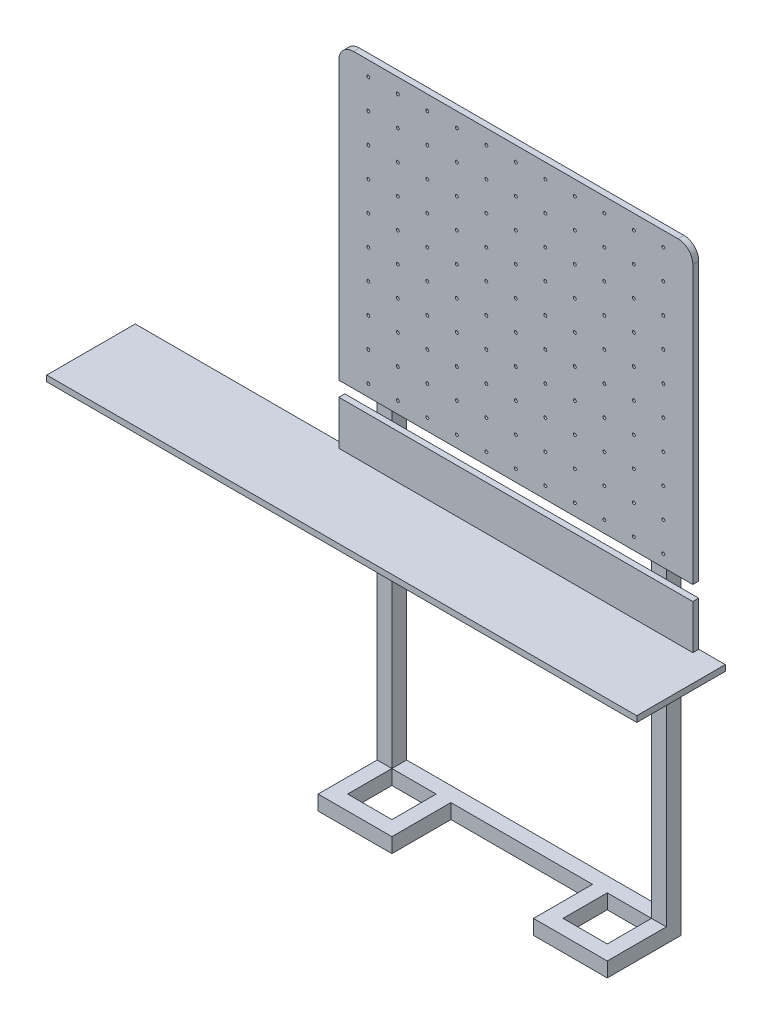
from build123d import *

# Parameters (mm, degrees)
CROQUIS1_W               = 1200
CROQUIS1_H               = 990
SALIENTE_EXTRUIR1_DEPTH  = 20
CROQUIS2_R               = 5
CORTAR_EXTRUIR1_DEPTH    = 21
CROQUIS3_W               = 50
CROQUIS3_H               = 50
SALIENTE_EXTRUIR2_DEPTH  = 50
CROQUIS7_W               = 50
CROQUIS7_H               = 50
SALIENTE_EXTRUIR4_DEPTH  = 2000
CROQUIS8_W               = 2000
CROQUIS8_H               = 20
SALIENTE_EXTRUIR5_DEPTH  = 300
CROQUIS9_W               = 1200
CROQUIS9_H               = 20
SALIENTE_EXTRUIR6_DEPTH  = 150
REDONDEO1_R              = 50
SALIENTE_EXTRUIR7_REACH  = 1752
CROQUIS10_W              = 50
CROQUIS10_H              = 50
SALIENTE_EXTRUIR8_REACH  = 1752
CROQUIS11_W              = 50
CROQUIS11_H              = 50
SALIENTE_EXTRUIR9_DEPTH  = 50
CROQUIS13_W              = 940
CROQUIS13_H              = 10
SALIENTE_EXTRUIR10_DEPTH = 10


with BuildPart() as part:
    # Croquis1 → Saliente-Extruir1 (new body)
    with BuildSketch(Plane.XY):
        Rectangle(CROQUIS1_W, CROQUIS1_H)
    extrude(amount=SALIENTE_EXTRUIR1_DEPTH)

    # Croquis2 → Cortar-Extruir1 (cut, through all)
    with BuildSketch(Plane.XY.offset(20)):
        with Locations((-500, 445)):
            Circle(CROQUIS2_R)
        with Locations((-400, 445)):
            Circle(CROQUIS2_R)
        with Locations((-300, 445)):
            Circle(CROQUIS2_R)
        with Locations((-200, 445)):
            Circle(CROQUIS2_R)
        with Locations((-100, 445)):
            Circle(CROQUIS2_R)
        with Locations((0, 445)):
            Circle(CROQUIS2_R)
        with Locations((100, 445)):
            Circle(CROQUIS2_R)
        with Locations((200, 445)):
            Circle(CROQUIS2_R)
        with Locations((300, 445)):
            Circle(CROQUIS2_R)
        with Locations((400, 445)):
            Circle(CROQUIS2_R)
        with Locations((500, 445)):
            Circle(CROQUIS2_R)
        with Locations((-400, 345)):
            Circle(CROQUIS2_R)
        with Locations((-300, 345)):
            Circle(CROQUIS2_R)
        with Locations((-200, 345)):
            Circle(CROQUIS2_R)
        with Locations((-100, 345)):
            Circle(CROQUIS2_R)
        with Locations((0, 345)):
            Circle(CROQUIS2_R)
        with Locations((100, 345)):
            Circle(CROQUIS2_R)
        with Locations((200, 345)):
            Circle(CROQUIS2_R)
        with Locations((300, 345)):
            Circle(CROQUIS2_R)
        with Locations((400, 345)):
            Circle(CROQUIS2_R)
        with Locations((500, 345)):
            Circle(CROQUIS2_R)
        with Locations((-400, 245)):
            Circle(CROQUIS2_R)
        with Locations((-300, 245)):
            Circle(CROQUIS2_R)
        with Locations((-200, 245)):
            Circle(CROQUIS2_R)
        with Locations((-100, 245)):
            Circle(CROQUIS2_R)
        with Locations((0, 245)):
            Circle(CROQUIS2_R)
        with Locations((100, 245)):
            Circle(CROQUIS2_R)
        with Locations((200, 245)):
            Circle(CROQUIS2_R)
        with Locations((300, 245)):
            Circle(CROQUIS2_R)
        with Locations((400, 245)):
            Circle(CROQUIS2_R)
        with Locations((500, 245)):
            Circle(CROQUIS2_R)
        with Locations((-400, 145)):
            Circle(CROQUIS2_R)
        with Locations((-300, 145)):
            Circle(CROQUIS2_R)
        with Locations((-200, 145)):
            Circle(CROQUIS2_R)
        with Locations((-100, 145)):
            Circle(CROQUIS2_R)
        with Locations((0, 145)):
            Circle(CROQUIS2_R)
        with Locations((100, 145)):
            Circle(CROQUIS2_R)
        with Locations((200, 145)):
            Circle(CROQUIS2_R)
        with Locations((300, 145)):
            Circle(CROQUIS2_R)
        with Locations((400, 145)):
            Circle(CROQUIS2_R)
        with Locations((500, 145)):
            Circle(CROQUIS2_R)
        with Locations((-400, 45)):
            Circle(CROQUIS2_R)
        with Locations((-300, 45)):
            Circle(CROQUIS2_R)
        with Locations((-200, 45)):
            Circle(CROQUIS2_R)
        with Locations((-100, 45)):
            Circle(CROQUIS2_R)
        with Locations((0, 45)):
            Circle(CROQUIS2_R)
        with Locations((100, 45)):
            Circle(CROQUIS2_R)
        with Locations((200, 45)):
            Circle(CROQUIS2_R)
        with Locations((300, 45)):
            Circle(CROQUIS2_R)
        with Locations((400, 45)):
            Circle(CROQUIS2_R)
        with Locations((500, 45)):
            Circle(CROQUIS2_R)
        with Locations((-400, -55)):
            Circle(CROQUIS2_R)
        with Locations((-300, -55)):
            Circle(CROQUIS2_R)
        with Locations((-200, -55)):
            Circle(CROQUIS2_R)
        with Locations((-100, -55)):
            Circle(CROQUIS2_R)
        with Locations((0, -55)):
            Circle(CROQUIS2_R)
        with Locations((100, -55)):
            Circle(CROQUIS2_R)
        with Locations((200, -55)):
            Circle(CROQUIS2_R)
        with Locations((300, -55)):
            Circle(CROQUIS2_R)
        with Locations((400, -55)):
            Circle(CROQUIS2_R)
        with Locations((500, -55)):
            Circle(CROQUIS2_R)
        with Locations((-400, -155)):
            Circle(CROQUIS2_R)
        with Locations((-300, -155)):
            Circle(CROQUIS2_R)
        with Locations((-200, -155)):
            Circle(CROQUIS2_R)
        with Locations((-100, -155)):
            Circle(CROQUIS2_R)
        with Locations((0, -155)):
            Circle(CROQUIS2_R)
        with Locations((100, -155)):
            Circle(CROQUIS2_R)
        with Locations((200, -155)):
            Circle(CROQUIS2_R)
        with Locations((300, -155)):
            Circle(CROQUIS2_R)
        with Locations((400, -155)):
            Circle(CROQUIS2_R)
        with Locations((500, -155)):
            Circle(CROQUIS2_R)
        with Locations((-400, -255)):
            Circle(CROQUIS2_R)
        with Locations((-300, -255)):
            Circle(CROQUIS2_R)
        with Locations((-200, -255)):
            Circle(CROQUIS2_R)
        with Locations((-100, -255)):
            Circle(CROQUIS2_R)
        with Locations((0, -255)):
            Circle(CROQUIS2_R)
        with Locations((100, -255)):
            Circle(CROQUIS2_R)
        with Locations((200, -255)):
            Circle(CROQUIS2_R)
        with Locations((300, -255)):
            Circle(CROQUIS2_R)
        with Locations((400, -255)):
            Circle(CROQUIS2_R)
        with Locations((500, -255)):
            Circle(CROQUIS2_R)
        with Locations((-400, -355)):
            Circle(CROQUIS2_R)
        with Locations((-300, -355)):
            Circle(CROQUIS2_R)
        with Locations((-200, -355)):
            Circle(CROQUIS2_R)
        with Locations((-100, -355)):
            Circle(CROQUIS2_R)
        with Locations((0, -355)):
            Circle(CROQUIS2_R)
        with Locations((100, -355)):
            Circle(CROQUIS2_R)
        with Locations((200, -355)):
            Circle(CROQUIS2_R)
        with Locations((300, -355)):
            Circle(CROQUIS2_R)
        with Locations((400, -355)):
            Circle(CROQUIS2_R)
        with Locations((500, -355)):
            Circle(CROQUIS2_R)
        with Locations((-400, -455)):
            Circle(CROQUIS2_R)
        with Locations((-300, -455)):
            Circle(CROQUIS2_R)
        with Locations((-200, -455)):
            Circle(CROQUIS2_R)
        with Locations((-100, -455)):
            Circle(CROQUIS2_R)
        with Locations((0, -455)):
            Circle(CROQUIS2_R)
        with Locations((100, -455)):
            Circle(CROQUIS2_R)
        with Locations((200, -455)):
            Circle(CROQUIS2_R)
        with Locations((300, -455)):
            Circle(CROQUIS2_R)
        with Locations((400, -455)):
            Circle(CROQUIS2_R)
        with Locations((500, -455)):
            Circle(CROQUIS2_R)
        with Locations((-500, 345)):
            Circle(CROQUIS2_R)
        with Locations((-500, 245)):
            Circle(CROQUIS2_R)
        with Locations((-500, 145)):
            Circle(CROQUIS2_R)
        with Locations((-500, 45)):
            Circle(CROQUIS2_R)
        with Locations((-500, -55)):
            Circle(CROQUIS2_R)
        with Locations((-500, -155)):
            Circle(CROQUIS2_R)
        with Locations((-500, -255)):
            Circle(CROQUIS2_R)
        with Locations((-500, -355)):
            Circle(CROQUIS2_R)
        with Locations((-500, -455)):
            Circle(CROQUIS2_R)
    extrude(amount=-CORTAR_EXTRUIR1_DEPTH, mode=Mode.SUBTRACT)

    # Croquis3 → Saliente-Extruir2 (add)
    with BuildSketch(Plane(origin=(0, 0, 0), x_dir=(-1, 0, 0), z_dir=(0, 0, -1))):
        with Locations((465, 410)):
            Rectangle(CROQUIS3_W, CROQUIS3_H)
        with Locations((-465, 410)):
            Rectangle(CROQUIS3_W, CROQUIS3_H)
    extrude(amount=SALIENTE_EXTRUIR2_DEPTH)

    # Croquis7 → Saliente-Extruir4 (add)
    with BuildSketch(Plane.XZ.offset(-385)):
        with Locations((465, -25)):
            Rectangle(CROQUIS7_W, CROQUIS7_H)
        with Locations((-465, -25)):
            Rectangle(CROQUIS7_W, CROQUIS7_H)
    extrude(amount=SALIENTE_EXTRUIR4_DEPTH)

    # Croquis8 → Saliente-Extruir5 (add)
    with BuildSketch(Plane.XY):
        with Locations((-310, -705)):
            Rectangle(CROQUIS8_W, CROQUIS8_H)
    extrude(amount=SALIENTE_EXTRUIR5_DEPTH)

    # Croquis9 → Saliente-Extruir6 (add)
    with BuildSketch(Plane(origin=(0, -695, 0), x_dir=(1, 0, 0), z_dir=(0, 1, 0))):
        with Locations((0, -10)):
            Rectangle(CROQUIS9_W, CROQUIS9_H)
    extrude(amount=SALIENTE_EXTRUIR6_DEPTH)

    # Redondeo1
    redondeo1_edges = [part.edges().sort_by_distance(p)[0] for p in [
        (-600, 495, 10),
        (600, 495, 10),
    ]]
    fillet(redondeo1_edges, radius=REDONDEO1_R)

    # Croquis10 → Saliente-Extruir7 (add, up to next)
    with BuildSketch(Plane.ZY.offset(-440), mode=Mode.PRIVATE) as saliente_extruir7_sk1:
        with Locations((-25, -1590)):
            Rectangle(CROQUIS10_W, CROQUIS10_H)
    saliente_extruir7_tool1 = extrude(saliente_extruir7_sk1.sketch, amount=SALIENTE_EXTRUIR7_REACH, mode=Mode.PRIVATE) - part.part
    add(saliente_extruir7_tool1.solids().sort_by_distance((440, -1590, -25))[0])

    # Croquis11 → Saliente-Extruir8 (add, up to next)
    with BuildSketch(Plane.ZY.offset(-440), mode=Mode.PRIVATE) as saliente_extruir8_sk1:
        with Locations((-25, -470)):
            Rectangle(CROQUIS11_W, CROQUIS11_H)
    saliente_extruir8_tool1 = extrude(saliente_extruir8_sk1.sketch, amount=SALIENTE_EXTRUIR8_REACH, mode=Mode.PRIVATE) - part.part
    add(saliente_extruir8_tool1.solids().sort_by_distance((440, -470, -25))[0])

    # Croquis12 → Saliente-Extruir9 (add)
    with BuildSketch(Plane.XZ.offset(1615)):
        Polygon((-490, 200), (-490, 0), (-440, 0), (-440, 150), (-290, 150), (-290, 0), (-240, 0), (-240, 200), align=None)
        Polygon((240, 200), (240, 0), (290, 0), (290, 150), (440, 150), (440, 0), (490, 0), (490, 200), align=None)
    extrude(amount=-SALIENTE_EXTRUIR9_DEPTH)

    # Croquis13 → Saliente-Extruir10 (add)
    with BuildSketch(Plane(origin=(0, 0, 0), x_dir=(-1, 0, 0), z_dir=(0, 0, -1))):
        with Locations((130, -310)):
            Rectangle(CROQUIS13_W, CROQUIS13_H)
    extrude(amount=SALIENTE_EXTRUIR10_DEPTH)


solid = part.part
